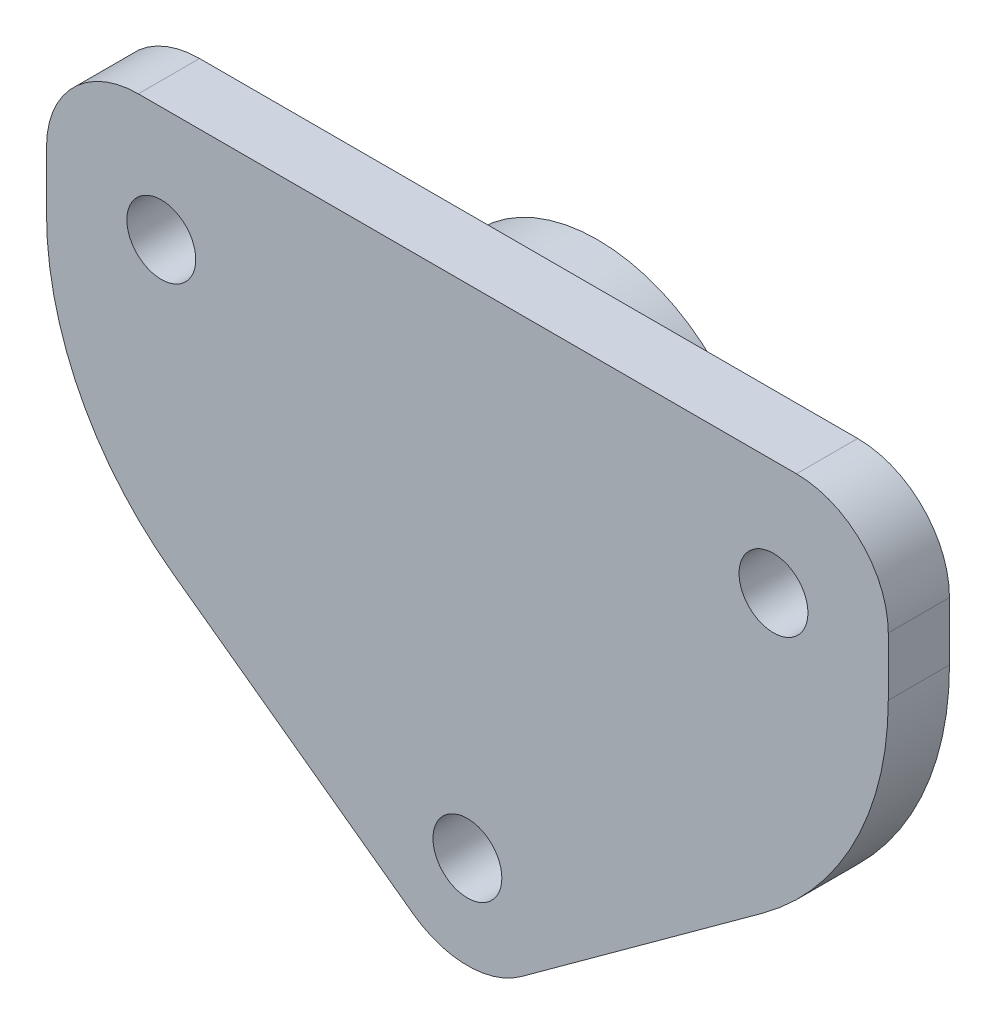
from build123d import *

# Parameters (mm, degrees)
ESQUISSE1_R        = 2.25
BOSS_EXTRU_1_DEPTH = 4
CONG_2_R           = 6
CONG_3_R           = 20
ESQUISSE2_R        = 10.75
BOSS_EXTRU_2_DEPTH = 4.5


with BuildPart() as part:
    # Esquisse1 → Boss.-Extru.1 (new body)
    with BuildSketch(Plane.XY):
        Polygon((-55, 20), (-27.5, 0), (0, 20), (0, 40), (-55, 40), align=None)
        with Locations((-47.5, 32.5)):
            Circle(ESQUISSE1_R, mode=Mode.SUBTRACT)
        with Locations((-7.5, 32.5)):
            Circle(ESQUISSE1_R, mode=Mode.SUBTRACT)
        with Locations((-27.5, 7.5)):
            Circle(ESQUISSE1_R, mode=Mode.SUBTRACT)
    extrude(amount=BOSS_EXTRU_1_DEPTH)

    # Congé2
    cong_2_edges = [part.edges().sort_by_distance(p)[0] for p in [
        (-55, 40, 2),
        (0, 40, 2),
        (-27.5, 0, 2),
    ]]
    fillet(cong_2_edges, radius=CONG_2_R)

    # Congé3
    cong_3_edges = [part.edges().sort_by_distance(p)[0] for p in [
        (0, 20, 2),
        (-55, 20, 2),
    ]]
    fillet(cong_3_edges, radius=CONG_3_R)

    # Esquisse2 → Boss.-Extru.2 (add)
    with BuildSketch(Plane(origin=(0, 0, 0), x_dir=(-1, 0, 0), z_dir=(0, 0, -1))):
        with Locations(Location((27.5, 27.5, 0), (0, 0, 180))):  # turned: the seam where the file's is
            Circle(ESQUISSE2_R)
    extrude(amount=BOSS_EXTRU_2_DEPTH)

    # Esquisse3 → Enlèvement de matière-Révolution5 (revolve, cut)
    with BuildSketch(Plane(origin=(0, 0, -4.5), x_dir=(-1, 0, 0), z_dir=(0, 0, -1))):
        with BuildLine():
            Line((27.5, 30.25), (27.5, 24.75))
            ThreePointArc((27.5, 24.75), (24.75, 27.5), (27.5, 30.25))
        make_face()
    revolve(axis=Axis((-27.5, 30.25, -4.5), (0, -1, 0)), mode=Mode.SUBTRACT)


solid = part.part
